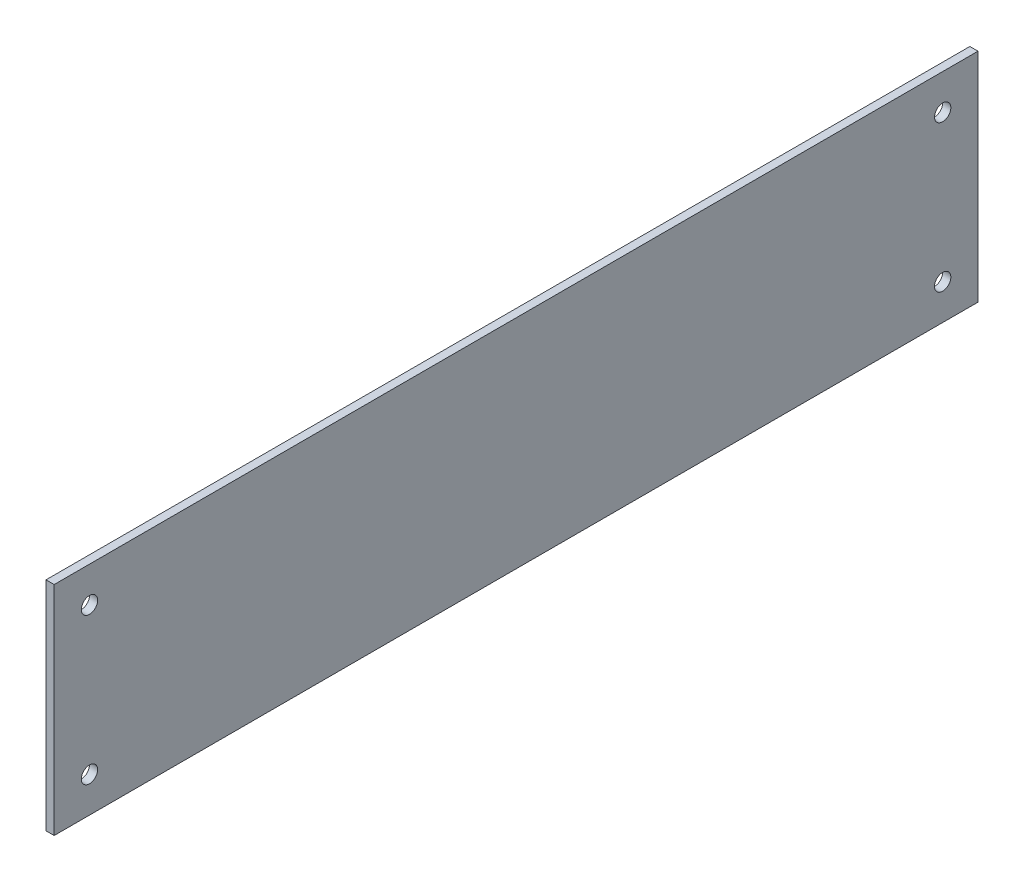
from build123d import *

# Parameters (mm, degrees)
SKETCH1_W               = 170
SKETCH1_H               = 40
BOSS_EXTRUDE1_DEPTH     = 1.5
SKETCH2_R               = 1.5
CUT_EXTRUDE1_DEPTH      = 15
CUT_EXTRUDE1_DEPTH_BACK = 15


with BuildPart() as part:
    # Sketch1 → Boss-Extrude1 (new body)
    with BuildSketch(Plane(origin=(0, 0, 0), x_dir=(0, 0, -1), z_dir=(1, 0, 0))):
        with Locations((85, 20)):
            Rectangle(SKETCH1_W, SKETCH1_H)
    extrude(amount=BOSS_EXTRUDE1_DEPTH)

    # Sketch2 → Cut-Extrude1 (cut, two sides)
    with BuildSketch(Plane(origin=(1.5, 0, 0), x_dir=(0, 0, -1), z_dir=(1, 0, 0))) as cut_extrude1_sk:
        with Locations((6.5, 6.5)):
            Circle(SKETCH2_R)
        with Locations((163.5, 6.5)):
            Circle(SKETCH2_R)
        with Locations((163.5, 33.5)):
            Circle(SKETCH2_R)
        with Locations((6.5, 33.5)):
            Circle(SKETCH2_R)
    extrude(amount=CUT_EXTRUDE1_DEPTH, mode=Mode.SUBTRACT)
    extrude(cut_extrude1_sk.sketch, amount=-CUT_EXTRUDE1_DEPTH_BACK, mode=Mode.SUBTRACT)


solid = part.part
